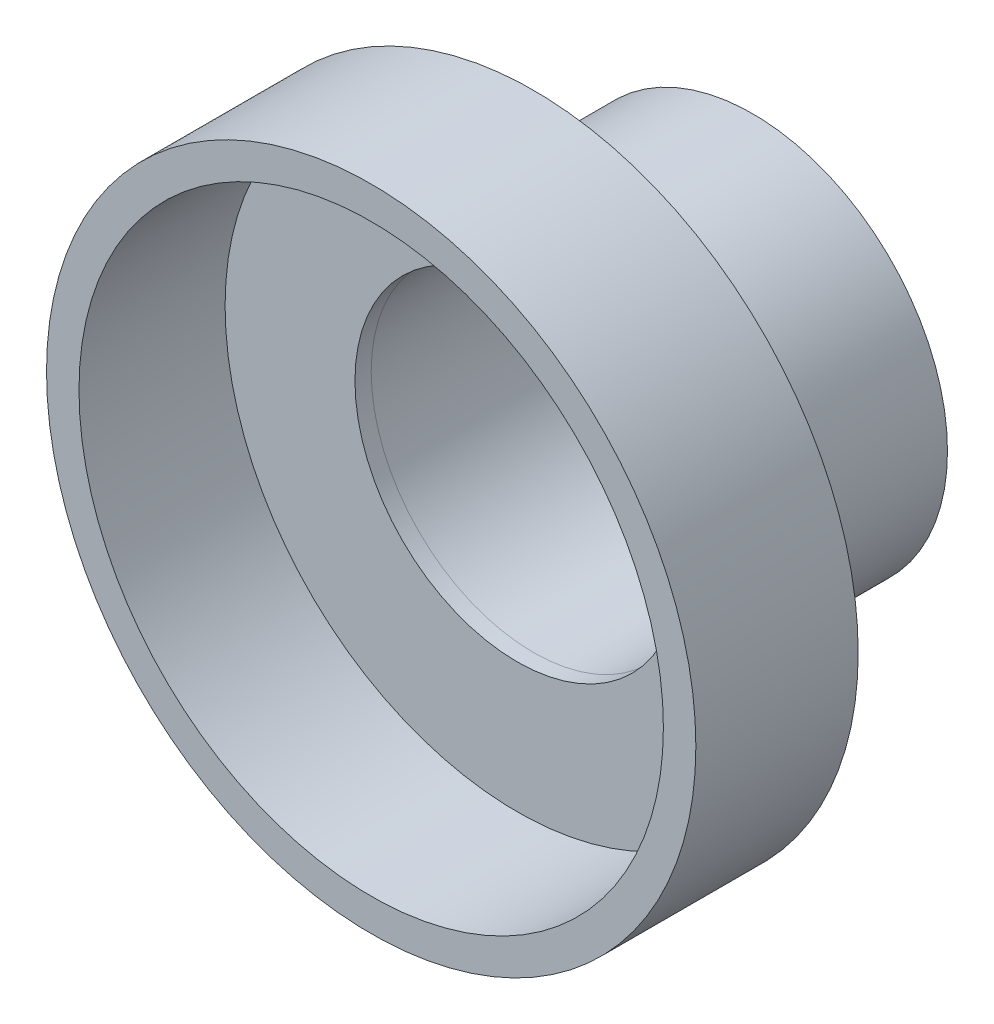
from build123d import *

# Parameters (mm, degrees)
SKETCH1_R           = 3
SKETCH1_R_2         = 2.5
BOSS_EXTRUDE1_DEPTH = 3.375
SKETCH2_R           = 5
SKETCH2_R_2         = 4.5
BOSS_EXTRUDE2_DEPTH = 2.5
SKETCH4_R           = 4.5
SKETCH4_R_2         = 2.5
BOSS_EXTRUDE5_DEPTH = 0.25


with BuildPart() as part:
    # Sketch1 → Boss-Extrude1 (new body)
    with BuildSketch(Plane.XY):
        Circle(SKETCH1_R)
        Circle(SKETCH1_R_2, mode=Mode.SUBTRACT)
    extrude(amount=BOSS_EXTRUDE1_DEPTH)


with BuildPart() as body_2:
    # Sketch2 → Boss-Extrude2 (new body)
    with BuildSketch(Plane.XY.offset(3.375)):
        Circle(SKETCH2_R)
        Circle(SKETCH2_R_2, mode=Mode.SUBTRACT)
    extrude(amount=BOSS_EXTRUDE2_DEPTH)

    # Sketch4 → Boss-Extrude5 (add)
    with BuildSketch(Plane.XY.offset(3.375)):
        Circle(SKETCH4_R)
        Circle(SKETCH4_R_2, mode=Mode.SUBTRACT)
    extrude(amount=BOSS_EXTRUDE5_DEPTH)


solid = Compound([part.part, body_2.part])
